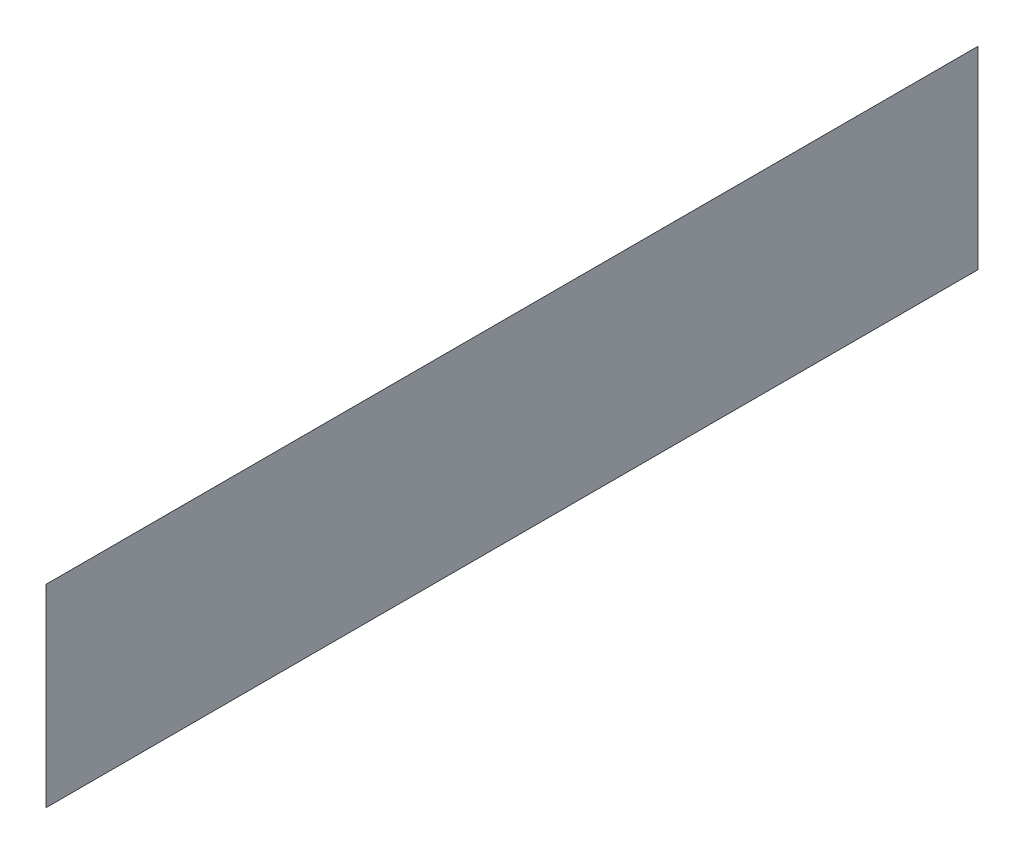
from build123d import *

# Parameters (mm, degrees)
BOSS_EXTRUDE1_DEPTH = 32.9
CUT_EXTRUDE1_DEPTH  = 275.9
BOSS_EXTRUDE2_DEPTH = 17.9


with BuildPart() as part:
    # Sketch1 → Boss-Extrude1 (new body)
    with BuildSketch(Plane(origin=(0, 0, 0), x_dir=(1, 0, 0), z_dir=(0, 1, 0))):
        Polygon((0, 244.7), (-32.901678529, 211.798321471), (-32.901678529, 32.901678529), (0, 0), align=None)
    extrude(amount=BOSS_EXTRUDE1_DEPTH)

    # Sketch2 → Cut-Extrude1 (cut)
    with BuildSketch(Plane.XY):
        Polygon((0, 32.9), (-32.901678529, 0), (-32.901678529, 32.9), align=None)
    extrude(amount=-CUT_EXTRUDE1_DEPTH, mode=Mode.SUBTRACT)

    # Sketch3 → Boss-Extrude2 (add)
    with BuildSketch(Plane.XZ):
        Polygon((0, 0), (-32.901678529, -32.901678529), (-32.901678529, -211.798321471), (0, -244.7), align=None)
    extrude(amount=BOSS_EXTRUDE2_DEPTH)


solid = part.part
